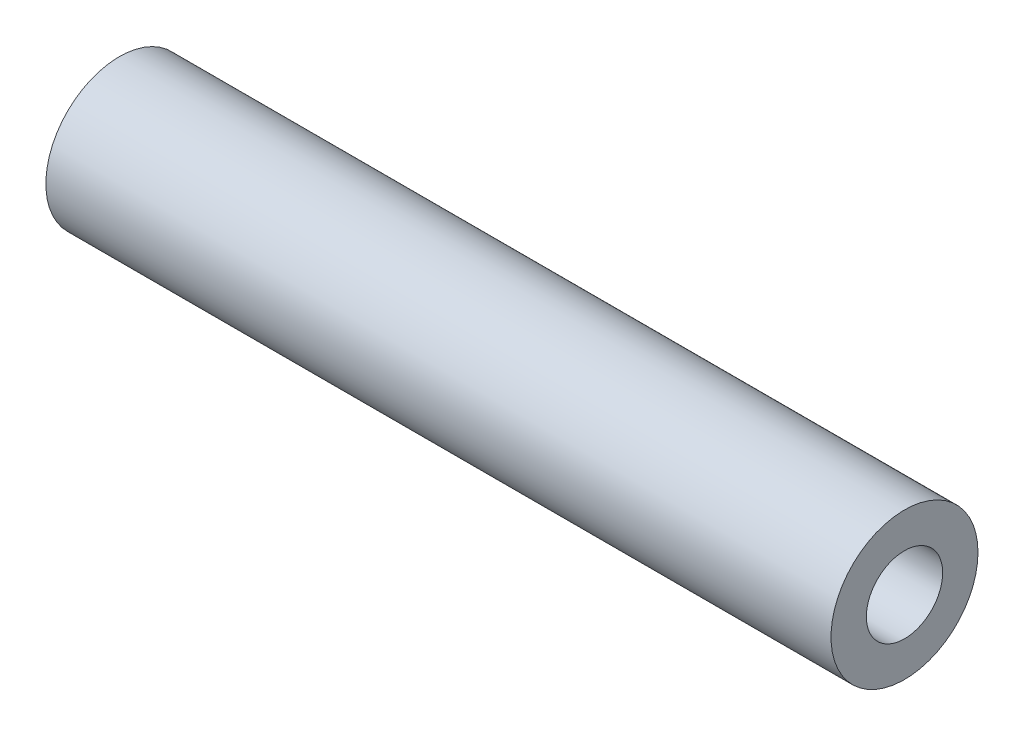
from build123d import *

# Parameters (mm, degrees)
SKETCH1_R           = 42.799
SKETCH1_R_2         = 22.225
BOSS_EXTRUDE1_DEPTH = 457.2


with BuildPart() as part:
    # Sketch1 → Boss-Extrude1 (new body)
    with BuildSketch(Plane(origin=(0, 0, 0), x_dir=(0, 0, -1), z_dir=(1, 0, 0))):
        Circle(SKETCH1_R)
        Circle(SKETCH1_R_2, mode=Mode.SUBTRACT)
    extrude(amount=BOSS_EXTRUDE1_DEPTH)


solid = part.part
